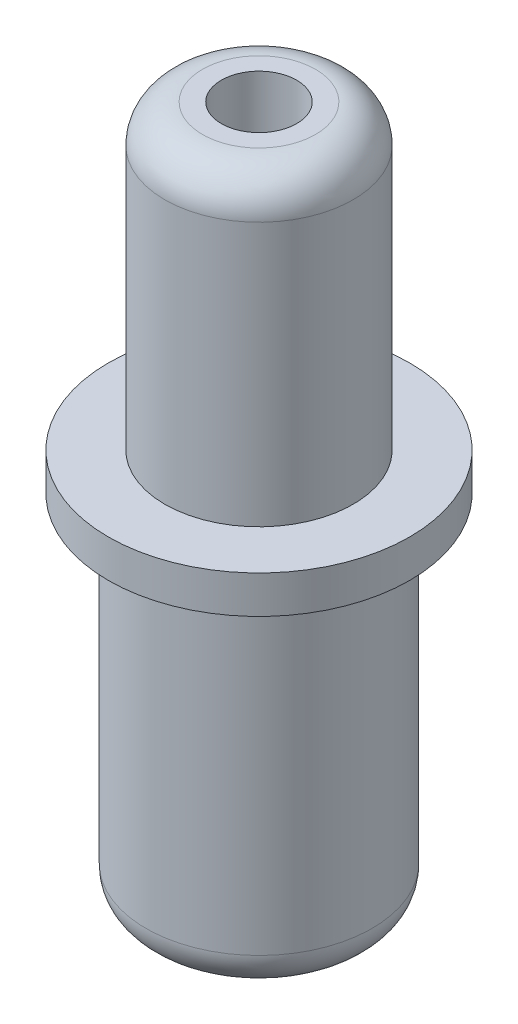
from build123d import *


with BuildPart() as part:
    # Эскиз1 → Повернуть1 (revolve)
    with BuildSketch(Plane(origin=(0, 0, 0), x_dir=(0, 0, -1), z_dir=(1, 0, 0))):
        with BuildLine():
            Line((2.5, 16), (2.5, 9))
            Line((2.5, 9), (4, 9))
            Line((4, 9), (4, 8))
            Line((4, 8), (3, 8))
            Line((3, 8), (3, -0.5))
            ThreePointArc((3, -0.5), (2.707106781, -1.207106781), (2, -1.5))
            Line((2, -1.5), (1, -1.5))
            Line((1, -1.5), (1, 17))
            Line((1, 17), (1.5, 17))
            ThreePointArc((1.5, 17), (2.207106781, 16.707106781), (2.5, 16))
        make_face()
    revolve(axis=Axis((0, 0, 0), (0, 1, 0)))


solid = part.part
